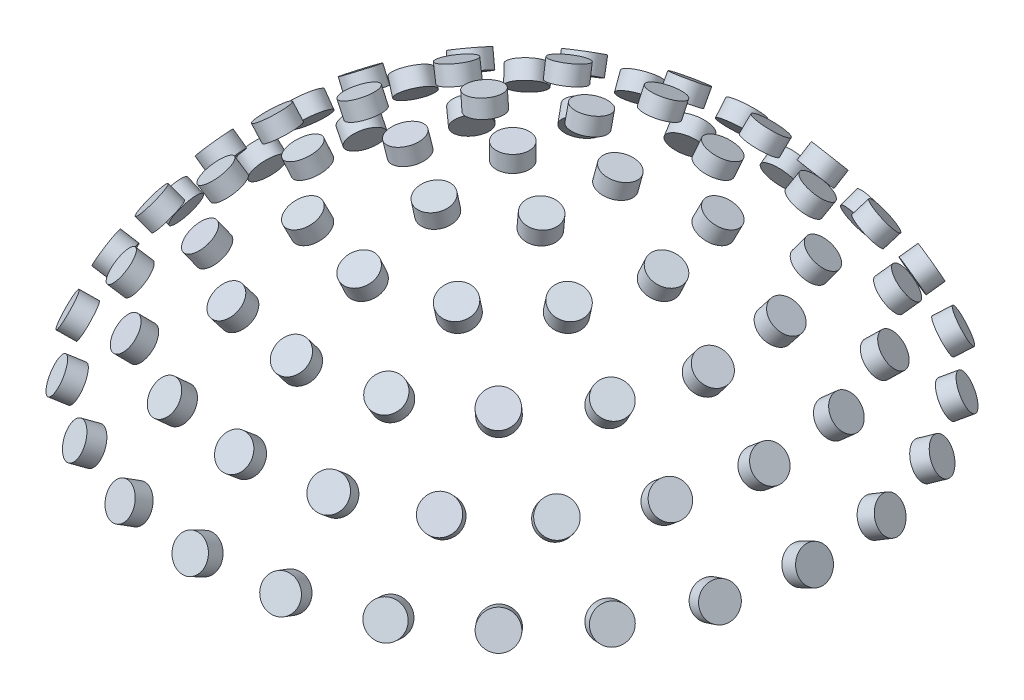
from build123d import *

# Parameters (mm, degrees)
SKETCH2_R           = 0.5
BOSS_EXTRUDE1_DEPTH = 0.5
CIRPATTERN1_COUNT   = 2
CIRPATTERN1_ANGLE   = 12.5
CIRPATTERN2_COUNT   = 2
CIRPATTERN2_ANGLE   = 25
CIRPATTERN3_COUNT   = 2
CIRPATTERN3_ANGLE   = 37.5
CIRPATTERN4_COUNT   = 2
CIRPATTERN4_ANGLE   = 50
CIRPATTERN5_COUNT   = 2
CIRPATTERN5_ANGLE   = 62.5
CIRPATTERN6_COUNT   = 6
CIRPATTERN7_COUNT   = 12
CIRPATTERN8_COUNT   = 17
CIRPATTERN9_COUNT   = 21
CIRPATTERN10_COUNT  = 25


with BuildPart() as part:
    # Sketch2 → Boss-Extrude1 (new body)
    with BuildSketch(Plane(origin=(0, 10.5, 0), x_dir=(1, 0, 0), z_dir=(0, 1, 0))):
        Circle(SKETCH2_R)
    extrude(amount=BOSS_EXTRUDE1_DEPTH)


with BuildPart() as cirpattern1_1:
    # CirPattern1: pattern copy
    add(part.part.rotate(Axis((0, 0, 0), (1, 0, 0)), 1 * CIRPATTERN1_ANGLE / (CIRPATTERN1_COUNT - 1)))


with BuildPart() as cirpattern2_1:
    # CirPattern2: pattern copy
    add(part.part.rotate(Axis((0, 0, 0), (1, 0, 0)), 1 * CIRPATTERN2_ANGLE / (CIRPATTERN2_COUNT - 1)))


with BuildPart() as cirpattern3_1:
    # CirPattern3: pattern copy
    add(part.part.rotate(Axis((0, 0, 0), (1, 0, 0)), 1 * CIRPATTERN3_ANGLE / (CIRPATTERN3_COUNT - 1)))


with BuildPart() as cirpattern4_1:
    # CirPattern4: pattern copy
    add(part.part.rotate(Axis((0, 0, 0), (1, 0, 0)), 1 * CIRPATTERN4_ANGLE / (CIRPATTERN4_COUNT - 1)))


with BuildPart() as cirpattern5_1:
    # CirPattern5: pattern copy
    add(part.part.rotate(Axis((0, 0, 0), (1, 0, 0)), 1 * CIRPATTERN5_ANGLE / (CIRPATTERN5_COUNT - 1)))


with BuildPart() as cirpattern6_1:
    # CirPattern6: pattern copy
    add(cirpattern1_1.part.rotate(Axis((0, 0, 0), (0, 1, 0)), 1 * 360 / CIRPATTERN6_COUNT))


with BuildPart() as cirpattern6_2:
    # CirPattern6: pattern copy
    add(cirpattern1_1.part.rotate(Axis((0, 0, 0), (0, 1, 0)), 2 * 360 / CIRPATTERN6_COUNT))


with BuildPart() as cirpattern6_3:
    # CirPattern6: pattern copy
    add(cirpattern1_1.part.rotate(Axis((0, 0, 0), (0, 1, 0)), 3 * 360 / CIRPATTERN6_COUNT))


with BuildPart() as cirpattern6_4:
    # CirPattern6: pattern copy
    add(cirpattern1_1.part.rotate(Axis((0, 0, 0), (0, 1, 0)), 4 * 360 / CIRPATTERN6_COUNT))


with BuildPart() as cirpattern6_5:
    # CirPattern6: pattern copy
    add(cirpattern1_1.part.rotate(Axis((0, 0, 0), (0, 1, 0)), 5 * 360 / CIRPATTERN6_COUNT))


with BuildPart() as cirpattern7_1:
    # CirPattern7: pattern copy
    add(cirpattern2_1.part.rotate(Axis((0, 0, 0), (0, 1, 0)), 1 * 360 / CIRPATTERN7_COUNT))


with BuildPart() as cirpattern7_2:
    # CirPattern7: pattern copy
    add(cirpattern2_1.part.rotate(Axis((0, 0, 0), (0, 1, 0)), 2 * 360 / CIRPATTERN7_COUNT))


with BuildPart() as cirpattern7_3:
    # CirPattern7: pattern copy
    add(cirpattern2_1.part.rotate(Axis((0, 0, 0), (0, 1, 0)), 3 * 360 / CIRPATTERN7_COUNT))


with BuildPart() as cirpattern7_4:
    # CirPattern7: pattern copy
    add(cirpattern2_1.part.rotate(Axis((0, 0, 0), (0, 1, 0)), 4 * 360 / CIRPATTERN7_COUNT))


with BuildPart() as cirpattern7_5:
    # CirPattern7: pattern copy
    add(cirpattern2_1.part.rotate(Axis((0, 0, 0), (0, 1, 0)), 5 * 360 / CIRPATTERN7_COUNT))


with BuildPart() as cirpattern7_6:
    # CirPattern7: pattern copy
    add(cirpattern2_1.part.rotate(Axis((0, 0, 0), (0, 1, 0)), 6 * 360 / CIRPATTERN7_COUNT))


with BuildPart() as cirpattern7_7:
    # CirPattern7: pattern copy
    add(cirpattern2_1.part.rotate(Axis((0, 0, 0), (0, 1, 0)), 7 * 360 / CIRPATTERN7_COUNT))


with BuildPart() as cirpattern7_8:
    # CirPattern7: pattern copy
    add(cirpattern2_1.part.rotate(Axis((0, 0, 0), (0, 1, 0)), 8 * 360 / CIRPATTERN7_COUNT))


with BuildPart() as cirpattern7_9:
    # CirPattern7: pattern copy
    add(cirpattern2_1.part.rotate(Axis((0, 0, 0), (0, 1, 0)), 9 * 360 / CIRPATTERN7_COUNT))


with BuildPart() as cirpattern7_10:
    # CirPattern7: pattern copy
    add(cirpattern2_1.part.rotate(Axis((0, 0, 0), (0, 1, 0)), 10 * 360 / CIRPATTERN7_COUNT))


with BuildPart() as cirpattern7_11:
    # CirPattern7: pattern copy
    add(cirpattern2_1.part.rotate(Axis((0, 0, 0), (0, 1, 0)), 11 * 360 / CIRPATTERN7_COUNT))


with BuildPart() as cirpattern8_1:
    # CirPattern8: pattern copy
    add(cirpattern3_1.part.rotate(Axis((0, 0, 0), (0, 1, 0)), 1 * 360 / CIRPATTERN8_COUNT))


with BuildPart() as cirpattern8_2:
    # CirPattern8: pattern copy
    add(cirpattern3_1.part.rotate(Axis((0, 0, 0), (0, 1, 0)), 2 * 360 / CIRPATTERN8_COUNT))


with BuildPart() as cirpattern8_3:
    # CirPattern8: pattern copy
    add(cirpattern3_1.part.rotate(Axis((0, 0, 0), (0, 1, 0)), 3 * 360 / CIRPATTERN8_COUNT))


with BuildPart() as cirpattern8_4:
    # CirPattern8: pattern copy
    add(cirpattern3_1.part.rotate(Axis((0, 0, 0), (0, 1, 0)), 4 * 360 / CIRPATTERN8_COUNT))


with BuildPart() as cirpattern8_5:
    # CirPattern8: pattern copy
    add(cirpattern3_1.part.rotate(Axis((0, 0, 0), (0, 1, 0)), 5 * 360 / CIRPATTERN8_COUNT))


with BuildPart() as cirpattern8_6:
    # CirPattern8: pattern copy
    add(cirpattern3_1.part.rotate(Axis((0, 0, 0), (0, 1, 0)), 6 * 360 / CIRPATTERN8_COUNT))


with BuildPart() as cirpattern8_7:
    # CirPattern8: pattern copy
    add(cirpattern3_1.part.rotate(Axis((0, 0, 0), (0, 1, 0)), 7 * 360 / CIRPATTERN8_COUNT))


with BuildPart() as cirpattern8_8:
    # CirPattern8: pattern copy
    add(cirpattern3_1.part.rotate(Axis((0, 0, 0), (0, 1, 0)), 8 * 360 / CIRPATTERN8_COUNT))


with BuildPart() as cirpattern8_9:
    # CirPattern8: pattern copy
    add(cirpattern3_1.part.rotate(Axis((0, 0, 0), (0, 1, 0)), 9 * 360 / CIRPATTERN8_COUNT))


with BuildPart() as cirpattern8_10:
    # CirPattern8: pattern copy
    add(cirpattern3_1.part.rotate(Axis((0, 0, 0), (0, 1, 0)), 10 * 360 / CIRPATTERN8_COUNT))


with BuildPart() as cirpattern8_11:
    # CirPattern8: pattern copy
    add(cirpattern3_1.part.rotate(Axis((0, 0, 0), (0, 1, 0)), 11 * 360 / CIRPATTERN8_COUNT))


with BuildPart() as cirpattern8_12:
    # CirPattern8: pattern copy
    add(cirpattern3_1.part.rotate(Axis((0, 0, 0), (0, 1, 0)), 12 * 360 / CIRPATTERN8_COUNT))


with BuildPart() as cirpattern8_13:
    # CirPattern8: pattern copy
    add(cirpattern3_1.part.rotate(Axis((0, 0, 0), (0, 1, 0)), 13 * 360 / CIRPATTERN8_COUNT))


with BuildPart() as cirpattern8_14:
    # CirPattern8: pattern copy
    add(cirpattern3_1.part.rotate(Axis((0, 0, 0), (0, 1, 0)), 14 * 360 / CIRPATTERN8_COUNT))


with BuildPart() as cirpattern8_15:
    # CirPattern8: pattern copy
    add(cirpattern3_1.part.rotate(Axis((0, 0, 0), (0, 1, 0)), 15 * 360 / CIRPATTERN8_COUNT))


with BuildPart() as cirpattern8_16:
    # CirPattern8: pattern copy
    add(cirpattern3_1.part.rotate(Axis((0, 0, 0), (0, 1, 0)), 16 * 360 / CIRPATTERN8_COUNT))


with BuildPart() as cirpattern9_1:
    # CirPattern9: pattern copy
    add(cirpattern4_1.part.rotate(Axis((0, 0, 0), (0, 1, 0)), 1 * 360 / CIRPATTERN9_COUNT))


with BuildPart() as cirpattern9_2:
    # CirPattern9: pattern copy
    add(cirpattern4_1.part.rotate(Axis((0, 0, 0), (0, 1, 0)), 2 * 360 / CIRPATTERN9_COUNT))


with BuildPart() as cirpattern9_3:
    # CirPattern9: pattern copy
    add(cirpattern4_1.part.rotate(Axis((0, 0, 0), (0, 1, 0)), 3 * 360 / CIRPATTERN9_COUNT))


with BuildPart() as cirpattern9_4:
    # CirPattern9: pattern copy
    add(cirpattern4_1.part.rotate(Axis((0, 0, 0), (0, 1, 0)), 4 * 360 / CIRPATTERN9_COUNT))


with BuildPart() as cirpattern9_5:
    # CirPattern9: pattern copy
    add(cirpattern4_1.part.rotate(Axis((0, 0, 0), (0, 1, 0)), 5 * 360 / CIRPATTERN9_COUNT))


with BuildPart() as cirpattern9_6:
    # CirPattern9: pattern copy
    add(cirpattern4_1.part.rotate(Axis((0, 0, 0), (0, 1, 0)), 6 * 360 / CIRPATTERN9_COUNT))


with BuildPart() as cirpattern9_7:
    # CirPattern9: pattern copy
    add(cirpattern4_1.part.rotate(Axis((0, 0, 0), (0, 1, 0)), 7 * 360 / CIRPATTERN9_COUNT))


with BuildPart() as cirpattern9_8:
    # CirPattern9: pattern copy
    add(cirpattern4_1.part.rotate(Axis((0, 0, 0), (0, 1, 0)), 8 * 360 / CIRPATTERN9_COUNT))


with BuildPart() as cirpattern9_9:
    # CirPattern9: pattern copy
    add(cirpattern4_1.part.rotate(Axis((0, 0, 0), (0, 1, 0)), 9 * 360 / CIRPATTERN9_COUNT))


with BuildPart() as cirpattern9_10:
    # CirPattern9: pattern copy
    add(cirpattern4_1.part.rotate(Axis((0, 0, 0), (0, 1, 0)), 10 * 360 / CIRPATTERN9_COUNT))


with BuildPart() as cirpattern9_11:
    # CirPattern9: pattern copy
    add(cirpattern4_1.part.rotate(Axis((0, 0, 0), (0, 1, 0)), 11 * 360 / CIRPATTERN9_COUNT))


with BuildPart() as cirpattern9_12:
    # CirPattern9: pattern copy
    add(cirpattern4_1.part.rotate(Axis((0, 0, 0), (0, 1, 0)), 12 * 360 / CIRPATTERN9_COUNT))


with BuildPart() as cirpattern9_13:
    # CirPattern9: pattern copy
    add(cirpattern4_1.part.rotate(Axis((0, 0, 0), (0, 1, 0)), 13 * 360 / CIRPATTERN9_COUNT))


with BuildPart() as cirpattern9_14:
    # CirPattern9: pattern copy
    add(cirpattern4_1.part.rotate(Axis((0, 0, 0), (0, 1, 0)), 14 * 360 / CIRPATTERN9_COUNT))


with BuildPart() as cirpattern9_15:
    # CirPattern9: pattern copy
    add(cirpattern4_1.part.rotate(Axis((0, 0, 0), (0, 1, 0)), 15 * 360 / CIRPATTERN9_COUNT))


with BuildPart() as cirpattern9_16:
    # CirPattern9: pattern copy
    add(cirpattern4_1.part.rotate(Axis((0, 0, 0), (0, 1, 0)), 16 * 360 / CIRPATTERN9_COUNT))


with BuildPart() as cirpattern9_17:
    # CirPattern9: pattern copy
    add(cirpattern4_1.part.rotate(Axis((0, 0, 0), (0, 1, 0)), 17 * 360 / CIRPATTERN9_COUNT))


with BuildPart() as cirpattern9_18:
    # CirPattern9: pattern copy
    add(cirpattern4_1.part.rotate(Axis((0, 0, 0), (0, 1, 0)), 18 * 360 / CIRPATTERN9_COUNT))


with BuildPart() as cirpattern9_19:
    # CirPattern9: pattern copy
    add(cirpattern4_1.part.rotate(Axis((0, 0, 0), (0, 1, 0)), 19 * 360 / CIRPATTERN9_COUNT))


with BuildPart() as cirpattern9_20:
    # CirPattern9: pattern copy
    add(cirpattern4_1.part.rotate(Axis((0, 0, 0), (0, 1, 0)), 20 * 360 / CIRPATTERN9_COUNT))


with BuildPart() as cirpattern10_1:
    # CirPattern10: pattern copy
    add(cirpattern5_1.part.rotate(Axis((0, 0, 0), (0, 1, 0)), 1 * 360 / CIRPATTERN10_COUNT))


with BuildPart() as cirpattern10_2:
    # CirPattern10: pattern copy
    add(cirpattern5_1.part.rotate(Axis((0, 0, 0), (0, 1, 0)), 2 * 360 / CIRPATTERN10_COUNT))


with BuildPart() as cirpattern10_3:
    # CirPattern10: pattern copy
    add(cirpattern5_1.part.rotate(Axis((0, 0, 0), (0, 1, 0)), 3 * 360 / CIRPATTERN10_COUNT))


with BuildPart() as cirpattern10_4:
    # CirPattern10: pattern copy
    add(cirpattern5_1.part.rotate(Axis((0, 0, 0), (0, 1, 0)), 4 * 360 / CIRPATTERN10_COUNT))


with BuildPart() as cirpattern10_5:
    # CirPattern10: pattern copy
    add(cirpattern5_1.part.rotate(Axis((0, 0, 0), (0, 1, 0)), 5 * 360 / CIRPATTERN10_COUNT))


with BuildPart() as cirpattern10_6:
    # CirPattern10: pattern copy
    add(cirpattern5_1.part.rotate(Axis((0, 0, 0), (0, 1, 0)), 6 * 360 / CIRPATTERN10_COUNT))


with BuildPart() as cirpattern10_7:
    # CirPattern10: pattern copy
    add(cirpattern5_1.part.rotate(Axis((0, 0, 0), (0, 1, 0)), 7 * 360 / CIRPATTERN10_COUNT))


with BuildPart() as cirpattern10_8:
    # CirPattern10: pattern copy
    add(cirpattern5_1.part.rotate(Axis((0, 0, 0), (0, 1, 0)), 8 * 360 / CIRPATTERN10_COUNT))


with BuildPart() as cirpattern10_9:
    # CirPattern10: pattern copy
    add(cirpattern5_1.part.rotate(Axis((0, 0, 0), (0, 1, 0)), 9 * 360 / CIRPATTERN10_COUNT))


with BuildPart() as cirpattern10_10:
    # CirPattern10: pattern copy
    add(cirpattern5_1.part.rotate(Axis((0, 0, 0), (0, 1, 0)), 10 * 360 / CIRPATTERN10_COUNT))


with BuildPart() as cirpattern10_11:
    # CirPattern10: pattern copy
    add(cirpattern5_1.part.rotate(Axis((0, 0, 0), (0, 1, 0)), 11 * 360 / CIRPATTERN10_COUNT))


with BuildPart() as cirpattern10_12:
    # CirPattern10: pattern copy
    add(cirpattern5_1.part.rotate(Axis((0, 0, 0), (0, 1, 0)), 12 * 360 / CIRPATTERN10_COUNT))


with BuildPart() as cirpattern10_13:
    # CirPattern10: pattern copy
    add(cirpattern5_1.part.rotate(Axis((0, 0, 0), (0, 1, 0)), 13 * 360 / CIRPATTERN10_COUNT))


with BuildPart() as cirpattern10_14:
    # CirPattern10: pattern copy
    add(cirpattern5_1.part.rotate(Axis((0, 0, 0), (0, 1, 0)), 14 * 360 / CIRPATTERN10_COUNT))


with BuildPart() as cirpattern10_15:
    # CirPattern10: pattern copy
    add(cirpattern5_1.part.rotate(Axis((0, 0, 0), (0, 1, 0)), 15 * 360 / CIRPATTERN10_COUNT))


with BuildPart() as cirpattern10_16:
    # CirPattern10: pattern copy
    add(cirpattern5_1.part.rotate(Axis((0, 0, 0), (0, 1, 0)), 16 * 360 / CIRPATTERN10_COUNT))


with BuildPart() as cirpattern10_17:
    # CirPattern10: pattern copy
    add(cirpattern5_1.part.rotate(Axis((0, 0, 0), (0, 1, 0)), 17 * 360 / CIRPATTERN10_COUNT))


with BuildPart() as cirpattern10_18:
    # CirPattern10: pattern copy
    add(cirpattern5_1.part.rotate(Axis((0, 0, 0), (0, 1, 0)), 18 * 360 / CIRPATTERN10_COUNT))


with BuildPart() as cirpattern10_19:
    # CirPattern10: pattern copy
    add(cirpattern5_1.part.rotate(Axis((0, 0, 0), (0, 1, 0)), 19 * 360 / CIRPATTERN10_COUNT))


with BuildPart() as cirpattern10_20:
    # CirPattern10: pattern copy
    add(cirpattern5_1.part.rotate(Axis((0, 0, 0), (0, 1, 0)), 20 * 360 / CIRPATTERN10_COUNT))


with BuildPart() as cirpattern10_21:
    # CirPattern10: pattern copy
    add(cirpattern5_1.part.rotate(Axis((0, 0, 0), (0, 1, 0)), 21 * 360 / CIRPATTERN10_COUNT))


with BuildPart() as cirpattern10_22:
    # CirPattern10: pattern copy
    add(cirpattern5_1.part.rotate(Axis((0, 0, 0), (0, 1, 0)), 22 * 360 / CIRPATTERN10_COUNT))


with BuildPart() as cirpattern10_23:
    # CirPattern10: pattern copy
    add(cirpattern5_1.part.rotate(Axis((0, 0, 0), (0, 1, 0)), 23 * 360 / CIRPATTERN10_COUNT))


with BuildPart() as cirpattern10_24:
    # CirPattern10: pattern copy
    add(cirpattern5_1.part.rotate(Axis((0, 0, 0), (0, 1, 0)), 24 * 360 / CIRPATTERN10_COUNT))


solid = Compound([part.part, cirpattern1_1.part, cirpattern2_1.part, cirpattern3_1.part, cirpattern4_1.part, cirpattern5_1.part, cirpattern6_1.part, cirpattern6_2.part, cirpattern6_3.part, cirpattern6_4.part, cirpattern6_5.part, cirpattern7_1.part, cirpattern7_2.part, cirpattern7_3.part, cirpattern7_4.part, cirpattern7_5.part, cirpattern7_6.part, cirpattern7_7.part, cirpattern7_8.part, cirpattern7_9.part, cirpattern7_10.part, cirpattern7_11.part, cirpattern8_1.part, cirpattern8_2.part, cirpattern8_3.part, cirpattern8_4.part, cirpattern8_5.part, cirpattern8_6.part, cirpattern8_7.part, cirpattern8_8.part, cirpattern8_9.part, cirpattern8_10.part, cirpattern8_11.part, cirpattern8_12.part, cirpattern8_13.part, cirpattern8_14.part, cirpattern8_15.part, cirpattern8_16.part, cirpattern9_1.part, cirpattern9_2.part, cirpattern9_3.part, cirpattern9_4.part, cirpattern9_5.part, cirpattern9_6.part, cirpattern9_7.part, cirpattern9_8.part, cirpattern9_9.part, cirpattern9_10.part, cirpattern9_11.part, cirpattern9_12.part, cirpattern9_13.part, cirpattern9_14.part, cirpattern9_15.part, cirpattern9_16.part, cirpattern9_17.part, cirpattern9_18.part, cirpattern9_19.part, cirpattern9_20.part, cirpattern10_1.part, cirpattern10_2.part, cirpattern10_3.part, cirpattern10_4.part, cirpattern10_5.part, cirpattern10_6.part, cirpattern10_7.part, cirpattern10_8.part, cirpattern10_9.part, cirpattern10_10.part, cirpattern10_11.part, cirpattern10_12.part, cirpattern10_13.part, cirpattern10_14.part, cirpattern10_15.part, cirpattern10_16.part, cirpattern10_17.part, cirpattern10_18.part, cirpattern10_19.part, cirpattern10_20.part, cirpattern10_21.part, cirpattern10_22.part, cirpattern10_23.part, cirpattern10_24.part])
